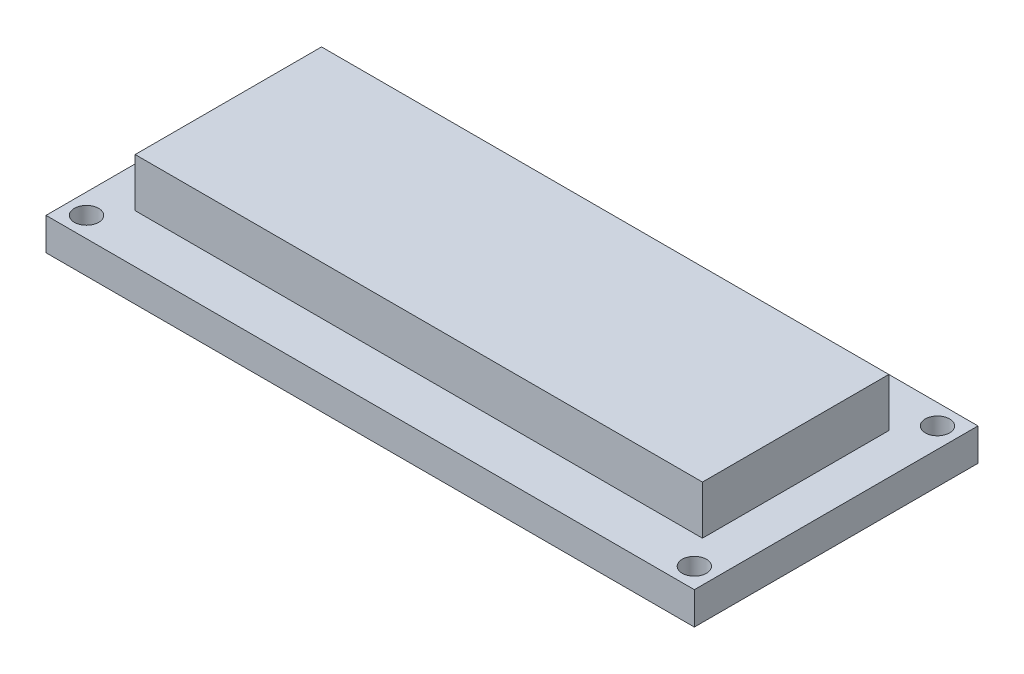
from build123d import *

# Parameters (mm, degrees)
SZKIC1_W                    = 80
SZKIC1_H                    = 35
SZKIC1_R                    = 1.5
DODANIE_WYCI_GNI_CIE1_DEPTH = 4
SZKIC2_W                    = 70
SZKIC2_H                    = 23
DODANIE_WYCI_GNI_CIE2_DEPTH = 6


with BuildPart() as part:
    # Szkic1 → Dodanie-wyciągnięcie1 (new body)
    with BuildSketch(Plane(origin=(0, 0, 0), x_dir=(1, 0, 0), z_dir=(0, 1, 0))):
        Rectangle(SZKIC1_W, SZKIC1_H)
        with Locations((-37.5, 15)):
            Circle(SZKIC1_R, mode=Mode.SUBTRACT)
        with Locations((-37.5, -15)):
            Circle(SZKIC1_R, mode=Mode.SUBTRACT)
        with Locations((37.5, -15)):
            Circle(SZKIC1_R, mode=Mode.SUBTRACT)
        with Locations((37.5, 15)):
            Circle(SZKIC1_R, mode=Mode.SUBTRACT)
    extrude(amount=DODANIE_WYCI_GNI_CIE1_DEPTH)

    # Szkic2 → Dodanie-wyciągnięcie2 (add)
    with BuildSketch(Plane(origin=(0, 4, 0), x_dir=(1, 0, 0), z_dir=(0, 1, 0))):
        Rectangle(SZKIC2_W, SZKIC2_H)
    extrude(amount=DODANIE_WYCI_GNI_CIE2_DEPTH)


solid = part.part
